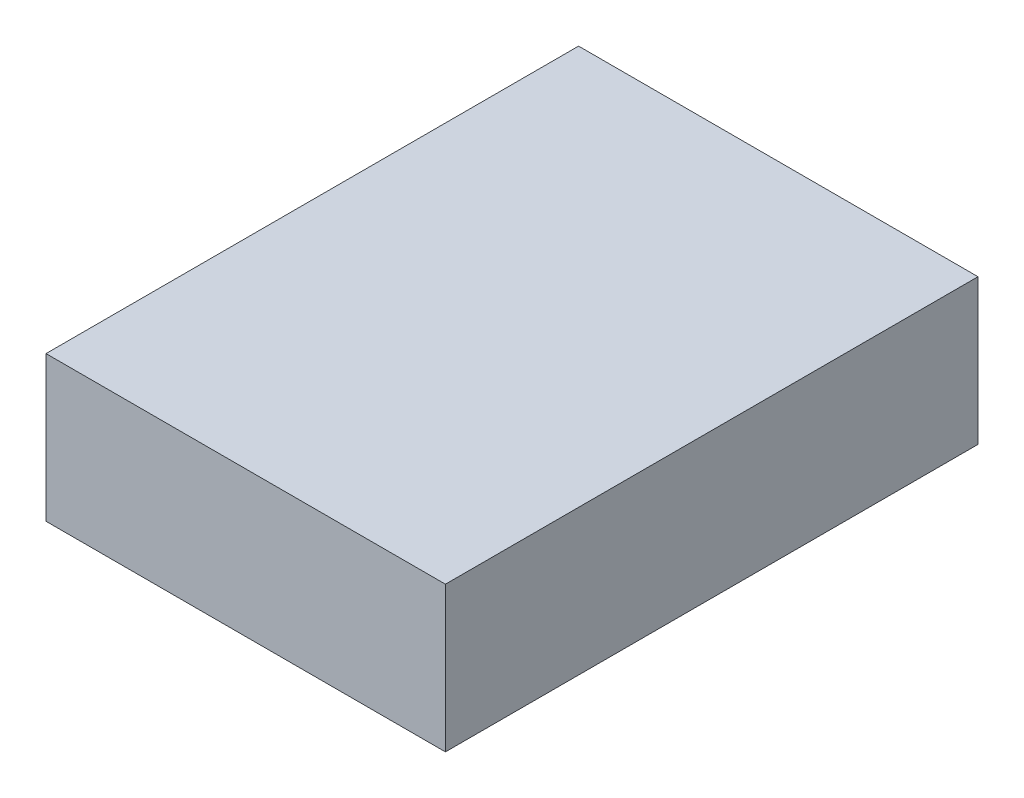
from build123d import *

# Parameters (mm, degrees)
SKETCH1_W           = 52.3875
SKETCH1_H           = 69.85
BOSS_EXTRUDE1_DEPTH = 19.05


with BuildPart() as part:
    # Sketch1 → Boss-Extrude1 (new body)
    with BuildSketch(Plane(origin=(0, 0, 0), x_dir=(1, 0, 0), z_dir=(0, 1, 0))):
        with Locations((26.19375, 34.925)):
            Rectangle(SKETCH1_W, SKETCH1_H)
    extrude(amount=BOSS_EXTRUDE1_DEPTH)


solid = part.part
